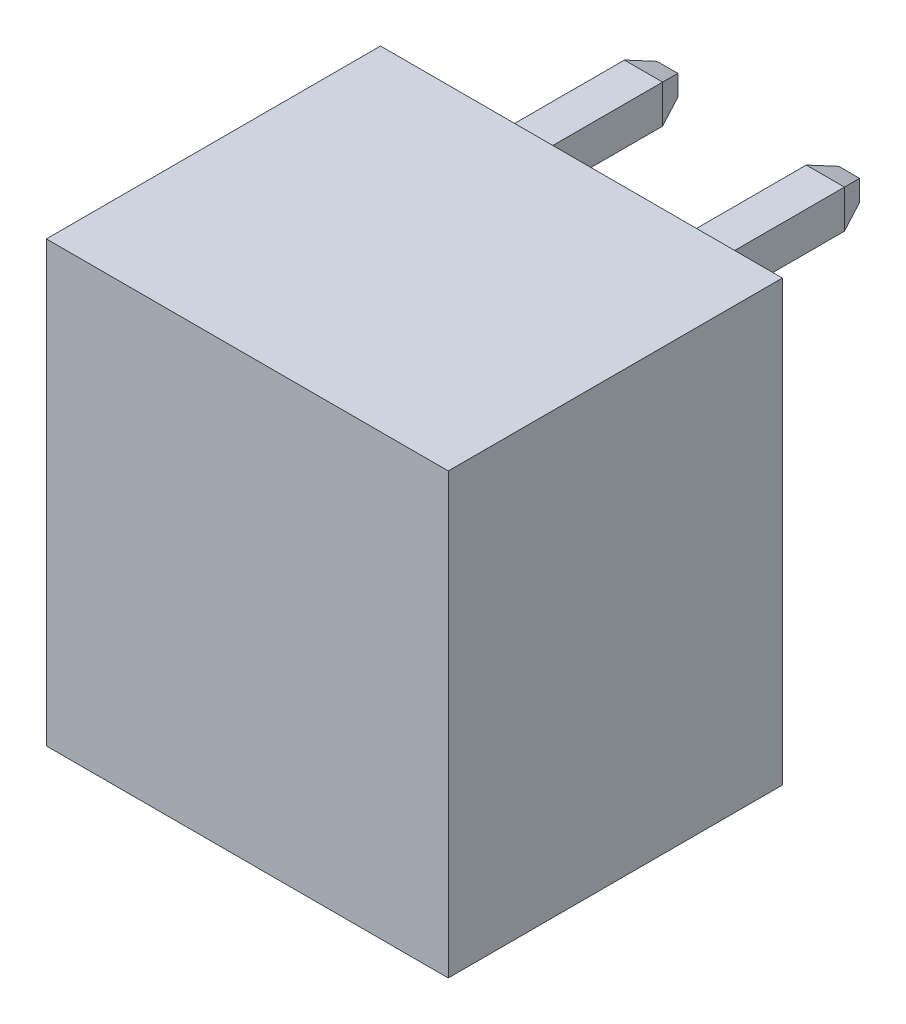
from build123d import *
from OCP.BRepFilletAPI import BRepFilletAPI_MakeChamfer

# Parameters (mm, degrees)
SKETCH1_W                    = 8.42
SKETCH1_H                    = 9.2
BOSS_EXTRUDE1_DEPTH          = 7
CUT_EXTRUDE1_DEPTH           = 7
LPATTERN1_COUNT              = 2
LPATTERN1_PITCH              = 3.81
SKETCH3_R                    = 0.875
BOSS_EXTRUDE2_DEPTH          = 1.15
CHAMFER1_SIZE                = 0.5
CHAMFER1_SIZE2               = 0.056791013
SKETCH4_W                    = 0.81
SKETCH4_H                    = 0.81
BOSS_EXTRUDE3_DEPTH          = 4.45
CHAMFER2_SIZE                = 0.5
CHAMFER2_SIZE2               = 0.181985117
LPATTERN3_COUNT              = 2
LPATTERN3_PITCH              = 3.81
CHAMFER1_OF_LPATTERN3_SIZE2  = 0.056791013
CHAMFER1_OF_LPATTERN3_SIZE   = 0.5
LPATTERN4_COUNT              = 2
LPATTERN4_PITCH              = 3.81
CHAMFER2_OF_LPATTERN4_SIZE   = 0.5
CHAMFER2_OF_LPATTERN4_SIZE2  = 0.181985117
BOSS_EXTRUDE4_START          = -3.4
SKETCH5_W                    = 0.8
SKETCH5_H                    = 0.8
BOSS_EXTRUDE4_DEPTH          = 7.1
CHAMFER3_SIZE                = 0.5
CHAMFER3_SIZE2               = 0.181985117
LPATTERN12_COUNT             = 2
LPATTERN12_PITCH             = 3.81
CHAMFER3_OF_LPATTERN12_SIZE  = 0.5
CHAMFER3_OF_LPATTERN12_SIZE2 = 0.181985117


with BuildPart() as part:
    # Sketch1 → Boss-Extrude1 (new body)
    with BuildSketch(Plane.XY):
        Rectangle(SKETCH1_W, SKETCH1_H)
    extrude(amount=BOSS_EXTRUDE1_DEPTH)

    # Sketch2 → Cut-Extrude1 (cut)
    with BuildSketch(Plane.XZ.offset(4.6)):
        with BuildLine():
            Line((-3.535, 5.11), (-2.705, 5.11))
            Line((-2.705, 5.11), (-2.705, 5.79))
            Line((-2.705, 5.79), (-3.205, 5.79))
            Line((-3.205, 5.79), (-3.353813394, 6.34))
            Line((-3.353813394, 6.34), (-0.456186606, 6.34))
            Line((-0.456186606, 6.34), (-0.605, 5.79))
            Line((-0.605, 5.79), (-1.105, 5.79))
            Line((-1.105, 5.79), (-1.105, 5.11))
            Line((-1.105, 5.11), (-0.275, 5.11))
            Line((-0.275, 5.11), (-0.275, 0.66))
            Line((-0.275, 0.66), (-0.965, 0.66))
            ThreePointArc((-0.965, 0.66), (-1.905, 0.904), (-2.845, 0.66))
            Line((-2.845, 0.66), (-3.535, 0.66))
            Line((-3.535, 0.66), (-3.535, 5.11))
        make_face()
    cut_extrude1 = extrude(amount=-CUT_EXTRUDE1_DEPTH, mode=Mode.SUBTRACT)

    # LPattern1: Cut-Extrude1 ×2
    with Locations(*[(i * LPATTERN1_PITCH, 0, 0) for i in range(1, LPATTERN1_COUNT)]):
        add(cut_extrude1, mode=Mode.SUBTRACT)

    # Sketch3 → Boss-Extrude2 (add)
    with BuildSketch(Plane.XZ.offset(-2.4)):
        with Locations(Location((-1.905, 2.985, 0), (0, 0, 90))):
            Circle(SKETCH3_R)
    boss_extrude2 = extrude(amount=BOSS_EXTRUDE2_DEPTH)

    # Chamfer1
    chamfer1_edges = [part.edges().sort_by_distance(p)[0] for p in [
        (-1.905, 1.25, 2.11),
    ]]
    chamfer1_side = [part.faces().sort_by_distance(p)[0] for p in [
        (-1.905, 1.825, 2.11),
    ]]
    chamfer(chamfer1_edges, length=CHAMFER1_SIZE, length2=CHAMFER1_SIZE2, reference=chamfer1_side[0])

    # Sketch4 → Boss-Extrude3 (add)
    with BuildSketch(Plane.XZ.offset(-1.25)):
        with Locations((-1.905, 2.985)):
            Rectangle(SKETCH4_W, SKETCH4_H)
    boss_extrude3 = extrude(amount=BOSS_EXTRUDE3_DEPTH)

    # Chamfer2: one chamfer whose edges measure the first distance from different faces: ONE call of the kernel's chamfer builder (chamfer() names one face for all edges)
    chamfer2_edges_1 = [part.edges().sort_by_distance(p)[0] for p in [
        (-1.5, -3.2, 2.985),
    ]]
    chamfer2_side_1 = [part.faces().sort_by_distance(p)[0] for p in [
        (-1.5, -0.975, 2.985),
    ]]
    chamfer2_edges_2 = [part.edges().sort_by_distance(p)[0] for p in [
        (-1.905, -3.2, 3.39),
    ]]
    chamfer2_side_2 = [part.faces().sort_by_distance(p)[0] for p in [
        (-1.905, -0.975, 3.39),
    ]]
    chamfer2_edges_3 = [part.edges().sort_by_distance(p)[0] for p in [
        (-2.31, -3.2, 2.985),
    ]]
    chamfer2_side_3 = [part.faces().sort_by_distance(p)[0] for p in [
        (-2.31, -0.975, 2.985),
    ]]
    chamfer2_edges_4 = [part.edges().sort_by_distance(p)[0] for p in [
        (-1.905, -3.2, 2.58),
    ]]
    chamfer2_side_4 = [part.faces().sort_by_distance(p)[0] for p in [
        (-1.905, -0.975, 2.58),
    ]]
    chamfer2 = BRepFilletAPI_MakeChamfer(part.part.solid().wrapped)
    for e in chamfer2_edges_1:
        chamfer2.Add(CHAMFER2_SIZE, CHAMFER2_SIZE2, e.wrapped, chamfer2_side_1[0].wrapped)  # the first distance lies on this face
    for e in chamfer2_edges_2:
        chamfer2.Add(CHAMFER2_SIZE, CHAMFER2_SIZE2, e.wrapped, chamfer2_side_2[0].wrapped)  # the first distance lies on this face
    for e in chamfer2_edges_3:
        chamfer2.Add(CHAMFER2_SIZE, CHAMFER2_SIZE2, e.wrapped, chamfer2_side_3[0].wrapped)  # the first distance lies on this face
    for e in chamfer2_edges_4:
        chamfer2.Add(CHAMFER2_SIZE, CHAMFER2_SIZE2, e.wrapped, chamfer2_side_4[0].wrapped)  # the first distance lies on this face
    add(Compound.cast(chamfer2.Shape()), mode=Mode.REPLACE)

    # LPattern3: Boss-Extrude2 ×2
    with Locations(*[(i * LPATTERN3_PITCH, 0, 0) for i in range(1, LPATTERN3_COUNT)]):
        add(boss_extrude2)

    # Chamfer1 of LPattern3
    chamfer1_of_lpattern3_edges = [part.edges().sort_by_distance(p)[0] for p in [
        (1.905, 1.25, 2.11),
    ]]
    chamfer(chamfer1_of_lpattern3_edges, length=CHAMFER1_OF_LPATTERN3_SIZE, length2=CHAMFER1_OF_LPATTERN3_SIZE2)

    # LPattern4: Boss-Extrude3 ×2
    with Locations(*[(i * LPATTERN4_PITCH, 0, 0) for i in range(1, LPATTERN4_COUNT)]):
        add(boss_extrude3)

    # Chamfer2 of LPattern4: one chamfer whose edges measure the first distance from different faces: ONE call of the kernel's chamfer builder (chamfer() names one face for all edges)
    chamfer2_of_lpattern4_edges_1 = [part.edges().sort_by_distance(p)[0] for p in [
        (2.31, -3.2, 2.985),
    ]]
    chamfer2_of_lpattern4_side_1 = [part.faces().sort_by_distance(p)[0] for p in [
        (2.31, -0.975, 2.985),
    ]]
    chamfer2_of_lpattern4_edges_2 = [part.edges().sort_by_distance(p)[0] for p in [
        (1.905, -3.2, 3.39),
    ]]
    chamfer2_of_lpattern4_side_2 = [part.faces().sort_by_distance(p)[0] for p in [
        (1.905, -0.975, 3.39),
    ]]
    chamfer2_of_lpattern4_edges_3 = [part.edges().sort_by_distance(p)[0] for p in [
        (1.5, -3.2, 2.985),
    ]]
    chamfer2_of_lpattern4_side_3 = [part.faces().sort_by_distance(p)[0] for p in [
        (1.5, -0.975, 2.985),
    ]]
    chamfer2_of_lpattern4_edges_4 = [part.edges().sort_by_distance(p)[0] for p in [
        (1.905, -3.2, 2.58),
    ]]
    chamfer2_of_lpattern4_side_4 = [part.faces().sort_by_distance(p)[0] for p in [
        (1.905, -0.975, 2.58),
    ]]
    chamfer2_of_lpattern4 = BRepFilletAPI_MakeChamfer(part.part.solid().wrapped)
    for e in chamfer2_of_lpattern4_edges_1:
        chamfer2_of_lpattern4.Add(CHAMFER2_OF_LPATTERN4_SIZE, CHAMFER2_OF_LPATTERN4_SIZE2, e.wrapped, chamfer2_of_lpattern4_side_1[0].wrapped)  # the first distance lies on this face
    for e in chamfer2_of_lpattern4_edges_2:
        chamfer2_of_lpattern4.Add(CHAMFER2_OF_LPATTERN4_SIZE, CHAMFER2_OF_LPATTERN4_SIZE2, e.wrapped, chamfer2_of_lpattern4_side_2[0].wrapped)  # the first distance lies on this face
    for e in chamfer2_of_lpattern4_edges_3:
        chamfer2_of_lpattern4.Add(CHAMFER2_OF_LPATTERN4_SIZE, CHAMFER2_OF_LPATTERN4_SIZE2, e.wrapped, chamfer2_of_lpattern4_side_3[0].wrapped)  # the first distance lies on this face
    for e in chamfer2_of_lpattern4_edges_4:
        chamfer2_of_lpattern4.Add(CHAMFER2_OF_LPATTERN4_SIZE, CHAMFER2_OF_LPATTERN4_SIZE2, e.wrapped, chamfer2_of_lpattern4_side_4[0].wrapped)  # the first distance lies on this face
    add(Compound.cast(chamfer2_of_lpattern4.Shape()), mode=Mode.REPLACE)

    # Sketch5 → Boss-Extrude4 (add)
    with BuildSketch(Plane(origin=(0, 0, 0), x_dir=(-1, 0, 0), z_dir=(0, 0, -1)).offset(BOSS_EXTRUDE4_START)):
        with Locations((1.9, 3.3)):
            Rectangle(SKETCH5_W, SKETCH5_H)
    boss_extrude4 = extrude(amount=BOSS_EXTRUDE4_DEPTH)

    # Chamfer3: one chamfer whose edges measure the first distance from different faces: ONE call of the kernel's chamfer builder (chamfer() names one face for all edges)
    chamfer3_edges_1 = [part.edges().sort_by_distance(p)[0] for p in [
        (-1.9, 2.9, -3.7),
    ]]
    chamfer3_side_1 = [part.faces().sort_by_distance(p)[0] for p in [
        (-1.9, 2.9, -1.85),
    ]]
    chamfer3_edges_2 = [part.edges().sort_by_distance(p)[0] for p in [
        (-1.5, 3.3, -3.7),
    ]]
    chamfer3_side_2 = [part.faces().sort_by_distance(p)[0] for p in [
        (-1.5, 3.3, -1.85),
    ]]
    chamfer3_edges_3 = [part.edges().sort_by_distance(p)[0] for p in [
        (-2.3, 3.3, -3.7),
    ]]
    chamfer3_side_3 = [part.faces().sort_by_distance(p)[0] for p in [
        (-2.3, 3.3, -1.85),
    ]]
    chamfer3_edges_4 = [part.edges().sort_by_distance(p)[0] for p in [
        (-1.9, 3.7, -3.7),
    ]]
    chamfer3_side_4 = [part.faces().sort_by_distance(p)[0] for p in [
        (-1.9, 3.7, -1.85),
    ]]
    chamfer3 = BRepFilletAPI_MakeChamfer(part.part.solid().wrapped)
    for e in chamfer3_edges_1:
        chamfer3.Add(CHAMFER3_SIZE, CHAMFER3_SIZE2, e.wrapped, chamfer3_side_1[0].wrapped)  # the first distance lies on this face
    for e in chamfer3_edges_2:
        chamfer3.Add(CHAMFER3_SIZE, CHAMFER3_SIZE2, e.wrapped, chamfer3_side_2[0].wrapped)  # the first distance lies on this face
    for e in chamfer3_edges_3:
        chamfer3.Add(CHAMFER3_SIZE, CHAMFER3_SIZE2, e.wrapped, chamfer3_side_3[0].wrapped)  # the first distance lies on this face
    for e in chamfer3_edges_4:
        chamfer3.Add(CHAMFER3_SIZE, CHAMFER3_SIZE2, e.wrapped, chamfer3_side_4[0].wrapped)  # the first distance lies on this face
    add(Compound.cast(chamfer3.Shape()), mode=Mode.REPLACE)

    # LPattern12: Boss-Extrude4 ×2
    with Locations(*[(i * LPATTERN12_PITCH, 0, 0) for i in range(1, LPATTERN12_COUNT)]):
        add(boss_extrude4)

    # Chamfer3 of LPattern12: one chamfer whose edges measure the first distance from different faces: ONE call of the kernel's chamfer builder (chamfer() names one face for all edges)
    chamfer3_of_lpattern12_edges_1 = [part.edges().sort_by_distance(p)[0] for p in [
        (1.91, 2.9, -3.7),
    ]]
    chamfer3_of_lpattern12_side_1 = [part.faces().sort_by_distance(p)[0] for p in [
        (1.91, 2.9, -1.85),
    ]]
    chamfer3_of_lpattern12_edges_2 = [part.edges().sort_by_distance(p)[0] for p in [
        (2.31, 3.3, -3.7),
    ]]
    chamfer3_of_lpattern12_side_2 = [part.faces().sort_by_distance(p)[0] for p in [
        (2.31, 3.3, -1.85),
    ]]
    chamfer3_of_lpattern12_edges_3 = [part.edges().sort_by_distance(p)[0] for p in [
        (1.51, 3.3, -3.7),
    ]]
    chamfer3_of_lpattern12_side_3 = [part.faces().sort_by_distance(p)[0] for p in [
        (1.51, 3.3, -1.85),
    ]]
    chamfer3_of_lpattern12_edges_4 = [part.edges().sort_by_distance(p)[0] for p in [
        (1.91, 3.7, -3.7),
    ]]
    chamfer3_of_lpattern12_side_4 = [part.faces().sort_by_distance(p)[0] for p in [
        (1.91, 3.7, -1.85),
    ]]
    chamfer3_of_lpattern12 = BRepFilletAPI_MakeChamfer(part.part.solid().wrapped)
    for e in chamfer3_of_lpattern12_edges_1:
        chamfer3_of_lpattern12.Add(CHAMFER3_OF_LPATTERN12_SIZE, CHAMFER3_OF_LPATTERN12_SIZE2, e.wrapped, chamfer3_of_lpattern12_side_1[0].wrapped)  # the first distance lies on this face
    for e in chamfer3_of_lpattern12_edges_2:
        chamfer3_of_lpattern12.Add(CHAMFER3_OF_LPATTERN12_SIZE, CHAMFER3_OF_LPATTERN12_SIZE2, e.wrapped, chamfer3_of_lpattern12_side_2[0].wrapped)  # the first distance lies on this face
    for e in chamfer3_of_lpattern12_edges_3:
        chamfer3_of_lpattern12.Add(CHAMFER3_OF_LPATTERN12_SIZE, CHAMFER3_OF_LPATTERN12_SIZE2, e.wrapped, chamfer3_of_lpattern12_side_3[0].wrapped)  # the first distance lies on this face
    for e in chamfer3_of_lpattern12_edges_4:
        chamfer3_of_lpattern12.Add(CHAMFER3_OF_LPATTERN12_SIZE, CHAMFER3_OF_LPATTERN12_SIZE2, e.wrapped, chamfer3_of_lpattern12_side_4[0].wrapped)  # the first distance lies on this face
    add(Compound.cast(chamfer3_of_lpattern12.Shape()), mode=Mode.REPLACE)


solid = part.part
